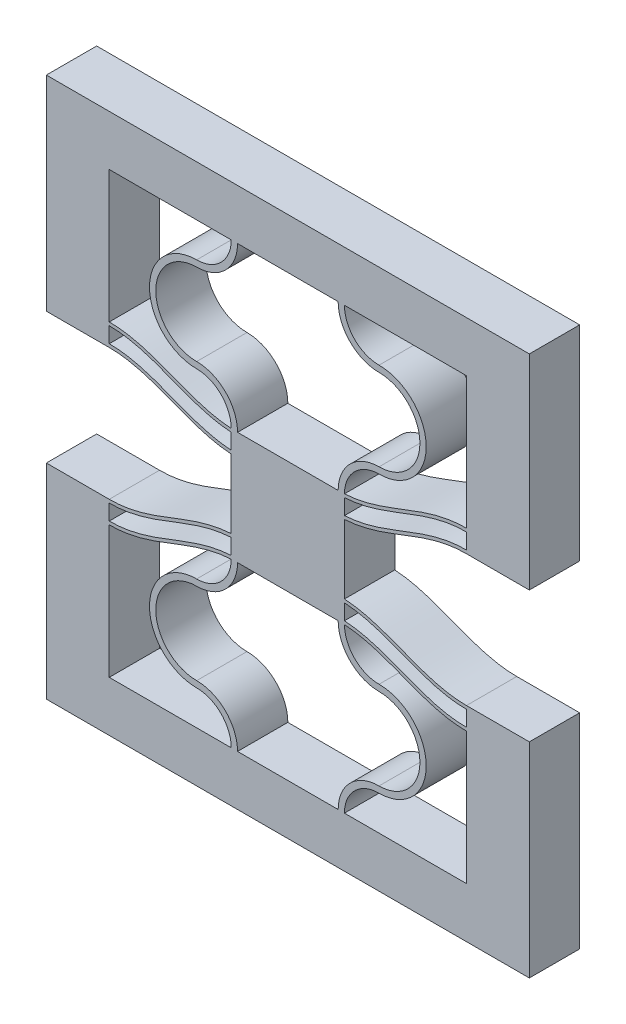
from build123d import *

# Parameters (mm, degrees)
BOSS_EXTRUDE1_DEPTH = 4
SKETCH4_W           = 1.000079602
SKETCH4_H           = 4
BOSS_EXTRUDE2_DEPTH = 1.5
SKETCH7_W           = 4
SKETCH7_H           = 4
SKETCH7_H_2         = 8.970409071
BOSS_EXTRUDE3_DEPTH = 4


with BuildPart() as part:
    # Sketch1 → Boss-Extrude1 (new body)
    with BuildSketch(Plane.XY):
        with BuildLine():
            add(Edge.make_bspline(
                [(10.700039975, 14.745204536), (10.770772559, 14.741026808), (11.036928883, 14.722362813), (11.497122592, 14.671037325), (12.289279781, 14.528352814), (13.186428125, 14.281886639), (13.972953946, 14.012479628), (14.659814487, 13.755888369), (15.208666695, 13.545451258), (15.665563716, 13.368818224), (16.123450769, 13.194753096), (16.65208653, 13.002369042), (17.160327646, 12.828079612), (17.673887847, 12.669729106), (18.193716878, 12.533320658), (18.599888692, 12.444944264), (18.888931626, 12.391496574), (19.130919694, 12.353423685), (19.325052629, 12.327000657), (19.519580514, 12.304753805), (19.715757224, 12.286804034), (19.909026191, 12.273251391), (20.101721437, 12.264172749), (20.275673832, 12.260758352), (20.359000366, 12.259999604), (20.4, 12.259999604)],
                knots=[0.519813033, 0.519813033, 0.519813033, 0.519813033, 0.519813033, 0.531036625, 0.562073255, 0.593109869, 0.647173692, 0.678210339, 0.693728663, 0.709246987, 0.740283631, 0.755801952, 0.771320274, 0.79835218, 0.825384086, 0.84090241, 0.856420734, 0.86417989, 0.871939045, 0.8796982, 0.887457356, 0.89521651, 0.902975665, 0.910734819, 0.918493974, 0.918493974, 0.918493974, 0.918493974, 0.918493974], degree=4))
            Line((10.700039975, 14.745204536), (10.700039975, 15.985204536))
            Line((10.700039975, 15.985204536), (9.699960373, 15.985204536))
            Line((9.699960373, 15.985204536), (9.699960373, 14.745204536))
            add(Edge.make_bspline(
                [(0, 12.259999604), (0.040999634, 12.259999604), (0.124259479, 12.260758348), (0.355363371, 12.265310827), (0.583318983, 12.278545215), (0.832717182, 12.299192103), (1.123166493, 12.332562429), (1.414830156, 12.374284724), (1.752116289, 12.434526897), (2.206359313, 12.533321163), (2.726048123, 12.669728195), (3.239713703, 12.828081076), (3.7478924, 13.002367086), (4.184493287, 13.161250769), (4.551277809, 13.299188315), (4.917195343, 13.439475144), (5.282809261, 13.580521779), (5.740185056, 13.755889696), (6.427046416, 14.012478612), (7.213571652, 14.281887279), (8.110720324, 14.528352483), (8.902877469, 14.671037458), (9.363071278, 14.722362846), (9.629227699, 14.741026811), (9.699960373, 14.745204536)],
                knots=[0.081506026, 0.081506026, 0.081506026, 0.081506026, 0.081506026, 0.089265181, 0.097024335, 0.112542644, 0.1203018, 0.128060955, 0.143579266, 0.15909759, 0.174615914, 0.20164782, 0.228679726, 0.244198048, 0.259716369, 0.275234691, 0.290753013, 0.306271337, 0.321789661, 0.352826308, 0.406890131, 0.437926745, 0.468963375, 0.480186981, 0.480186981, 0.480186981, 0.480186981, 0.480186981], degree=4))
            Line((0, 12.259999604), (-5.000000005, 12.259999604))
            Line((-5.000000005, 12.259999604), (-5.000000005, -4))
            Line((-5.000000005, -4), (25.400000005, -4))
            Line((25.400000005, -4), (25.400000005, 12.259999604))
            Line((25.400000005, 12.259999604), (20.4, 12.259999604))
        make_face()
        with BuildLine():
            Line((9.699960373, 14.485204536), (9.699960373, 13.245204536))
            add(Edge.make_bspline(
                [(0, 10.759999604), (0.040999634, 10.759999604), (0.124259479, 10.760758348), (0.355363371, 10.765310827), (0.583318983, 10.778545215), (0.832717182, 10.799192103), (1.123166493, 10.832562429), (1.414830156, 10.874284724), (1.752116289, 10.934526897), (2.206359313, 11.033321163), (2.726048123, 11.169728195), (3.239713703, 11.328081076), (3.7478924, 11.502367086), (4.184493287, 11.661250769), (4.551277809, 11.799188315), (4.917195343, 11.939475144), (5.282809261, 12.080521779), (5.740185056, 12.255889696), (6.427046416, 12.512478612), (7.213571652, 12.781887279), (8.110720324, 13.028352483), (8.902877469, 13.171037458), (9.363071278, 13.222362846), (9.629227699, 13.241026811), (9.699960373, 13.245204536)],
                knots=[0.081506026, 0.081506026, 0.081506026, 0.081506026, 0.081506026, 0.089265181, 0.097024335, 0.112542644, 0.1203018, 0.128060955, 0.143579266, 0.15909759, 0.174615914, 0.20164782, 0.228679726, 0.244198048, 0.259716369, 0.275234691, 0.290753013, 0.306271337, 0.321789661, 0.352826308, 0.406890131, 0.437926745, 0.468963375, 0.480186981, 0.480186981, 0.480186981, 0.480186981, 0.480186981], degree=4))
            Line((0, 10.759999604), (0, 11.999999604))
            add(Edge.make_bspline(
                [(0, 11.999999604), (0.040999634, 11.999999604), (0.124259479, 12.000758348), (0.355363371, 12.005310827), (0.583318983, 12.018545215), (0.832717182, 12.039192103), (1.123166493, 12.072562429), (1.414830156, 12.114284724), (1.752116289, 12.174526897), (2.206359313, 12.273321163), (2.726048123, 12.409728195), (3.239713703, 12.568081076), (3.7478924, 12.742367086), (4.184493287, 12.901250769), (4.551277809, 13.039188315), (4.917195343, 13.179475144), (5.282809261, 13.320521779), (5.740185056, 13.495889696), (6.427046416, 13.752478612), (7.213571652, 14.021887279), (8.110720324, 14.268352483), (8.902877469, 14.411037458), (9.363071278, 14.462362846), (9.629227699, 14.481026811), (9.699960373, 14.485204536)],
                knots=[0.081506026, 0.081506026, 0.081506026, 0.081506026, 0.081506026, 0.089265181, 0.097024335, 0.112542644, 0.1203018, 0.128060955, 0.143579266, 0.15909759, 0.174615914, 0.20164782, 0.228679726, 0.244198048, 0.259716369, 0.275234691, 0.290753013, 0.306271337, 0.321789661, 0.352826308, 0.406890131, 0.437926745, 0.468963375, 0.480186981, 0.480186981, 0.480186981, 0.480186981, 0.480186981], degree=4))
        make_face(mode=Mode.SUBTRACT)
        with BuildLine():
            Line((10.700039975, 13.245204536), (10.700039975, 14.485204536))
            add(Edge.make_bspline(
                [(10.700039975, 14.485204536), (10.770772559, 14.481026808), (11.036928883, 14.462362813), (11.497122592, 14.411037325), (12.289279781, 14.268352814), (13.186428125, 14.021886639), (13.972953947, 13.752479628), (14.659814487, 13.495888369), (15.208666695, 13.285451258), (15.665563716, 13.108818224), (16.123450769, 12.934753096), (16.65208653, 12.742369042), (17.160327646, 12.568079612), (17.673887847, 12.409729106), (18.193716878, 12.273320658), (18.599888692, 12.184944264), (18.888931626, 12.131496574), (19.130919694, 12.093423685), (19.325052629, 12.067000657), (19.519580514, 12.044753805), (19.715757224, 12.026804034), (19.909026191, 12.013251391), (20.101721437, 12.004172749), (20.275673832, 12.000758352), (20.359000366, 11.999999604), (20.4, 11.999999604)],
                knots=[0.519813033, 0.519813033, 0.519813033, 0.519813033, 0.519813033, 0.531036625, 0.562073255, 0.593109869, 0.647173692, 0.678210339, 0.693728663, 0.709246987, 0.740283631, 0.755801952, 0.771320274, 0.79835218, 0.825384086, 0.84090241, 0.856420734, 0.86417989, 0.871939045, 0.8796982, 0.887457356, 0.89521651, 0.902975665, 0.910734819, 0.918493974, 0.918493974, 0.918493974, 0.918493974, 0.918493974], degree=4))
            Line((20.4, 11.999999604), (20.4, 10.759999604))
            add(Edge.make_bspline(
                [(10.700039975, 13.245204536), (10.770772559, 13.241026808), (11.036928883, 13.222362813), (11.497122592, 13.171037325), (12.289279781, 13.028352814), (13.186428125, 12.781886639), (13.972953947, 12.512479628), (14.659814487, 12.255888369), (15.208666695, 12.045451258), (15.665563716, 11.868818224), (16.123450769, 11.694753096), (16.65208653, 11.502369042), (17.160327646, 11.328079612), (17.673887847, 11.169729106), (18.193716878, 11.033320658), (18.599888692, 10.944944264), (18.888931626, 10.891496574), (19.130919694, 10.853423685), (19.325052629, 10.827000657), (19.519580514, 10.804753805), (19.715757224, 10.786804034), (19.909026191, 10.773251391), (20.101721437, 10.764172749), (20.275673832, 10.760758352), (20.359000366, 10.759999604), (20.4, 10.759999604)],
                knots=[0.519813033, 0.519813033, 0.519813033, 0.519813033, 0.519813033, 0.531036625, 0.562073255, 0.593109869, 0.647173692, 0.678210339, 0.693728663, 0.709246987, 0.740283631, 0.755801952, 0.771320274, 0.79835218, 0.825384086, 0.84090241, 0.856420734, 0.86417989, 0.871939045, 0.8796982, 0.887457356, 0.89521651, 0.902975665, 0.910734819, 0.918493974, 0.918493974, 0.918493974, 0.918493974, 0.918493974], degree=4))
        make_face(mode=Mode.SUBTRACT)
        with BuildLine():
            Line((0, 0), (0, 10.499999604))
            add(Edge.make_bspline(
                [(0, 10.499999604), (0.040999634, 10.499999604), (0.124259479, 10.500758348), (0.355363371, 10.505310827), (0.583318983, 10.518545215), (0.832717182, 10.539192103), (1.123166493, 10.572562429), (1.414830156, 10.614284724), (1.752116289, 10.674526897), (2.206359313, 10.773321163), (2.726048123, 10.909728195), (3.239713703, 11.068081076), (3.7478924, 11.242367086), (4.184493287, 11.401250769), (4.551277809, 11.539188315), (4.917195343, 11.679475144), (5.282809261, 11.820521779), (5.740185056, 11.995889696), (6.427046416, 12.252478612), (7.213571652, 12.521887279), (8.110720324, 12.768352483), (8.902877469, 12.911037458), (9.363071278, 12.962362846), (9.629227699, 12.981026811), (9.699960373, 12.985204536)],
                knots=[0.081506026, 0.081506026, 0.081506026, 0.081506026, 0.081506026, 0.089265181, 0.097024335, 0.112542644, 0.1203018, 0.128060955, 0.143579266, 0.15909759, 0.174615914, 0.20164782, 0.228679726, 0.244198048, 0.259716369, 0.275234691, 0.290753013, 0.306271337, 0.321789661, 0.352826308, 0.406890131, 0.437926745, 0.468963375, 0.480186981, 0.480186981, 0.480186981, 0.480186981, 0.480186981], degree=4))
            ThreePointArc((9.699960373, 12.985204536), (8.889305781, 11.050232382), (6.950000174, 10.25))
            ThreePointArc((6.950000174, 10.25), (3.200000174, 6.5), (6.950000174, 2.75))
            ThreePointArc((6.950000174, 2.75), (8.894543822, 1.944543648), (9.700000174, 0))
            Line((9.700000174, 0), (0, 0))
        make_face(mode=Mode.SUBTRACT)
        with BuildLine():
            ThreePointArc((6.950000174, 9.75), (9.248097213, 10.701902961), (10.200000174, 13))
            ThreePointArc((10.200000174, 13), (11.151903135, 10.701902961), (13.450000174, 9.75))
            ThreePointArc((13.450000174, 9.75), (16.700000174, 6.5), (13.450000174, 3.25))
            ThreePointArc((13.450000174, 3.25), (11.151903135, 2.298097039), (10.200000174, 0))
            ThreePointArc((10.200000174, 0), (9.248097213, 2.298097039), (6.950000174, 3.25))
            ThreePointArc((6.950000174, 3.25), (3.700000174, 6.5), (6.950000174, 9.75))
        make_face(mode=Mode.SUBTRACT)
        with BuildLine():
            ThreePointArc((13.450000174, 10.25), (11.510694567, 11.050232382), (10.700039975, 12.985204536))
            add(Edge.make_bspline(
                [(10.700039975, 12.985204536), (10.770772559, 12.981026808), (11.036928883, 12.962362813), (11.497122592, 12.911037325), (12.289279781, 12.768352814), (13.186428125, 12.521886639), (13.972953947, 12.252479628), (14.659814487, 11.995888369), (15.208666695, 11.785451258), (15.665563716, 11.608818224), (16.123450769, 11.434753096), (16.65208653, 11.242369042), (17.160327646, 11.068079612), (17.673887847, 10.909729106), (18.193716878, 10.773320658), (18.599888692, 10.684944264), (18.888931626, 10.631496574), (19.130919694, 10.593423685), (19.325052629, 10.567000657), (19.519580514, 10.544753805), (19.715757224, 10.526804034), (19.909026191, 10.513251391), (20.101721437, 10.504172749), (20.275673832, 10.500758352), (20.359000366, 10.499999604), (20.4, 10.499999604)],
                knots=[0.519813033, 0.519813033, 0.519813033, 0.519813033, 0.519813033, 0.531036625, 0.562073255, 0.593109869, 0.647173692, 0.678210339, 0.693728663, 0.709246987, 0.740283631, 0.755801952, 0.771320274, 0.79835218, 0.825384086, 0.84090241, 0.856420734, 0.86417989, 0.871939045, 0.8796982, 0.887457356, 0.89521651, 0.902975665, 0.910734819, 0.918493974, 0.918493974, 0.918493974, 0.918493974, 0.918493974], degree=4))
            Line((20.4, 10.499999604), (20.4, 0))
            Line((20.4, 0), (10.700000174, 0))
            ThreePointArc((10.700000174, 0), (11.505456526, 1.944543648), (13.450000174, 2.75))
            ThreePointArc((13.450000174, 2.75), (17.200000174, 6.5), (13.450000174, 10.25))
        make_face(mode=Mode.SUBTRACT)
    extrude(amount=BOSS_EXTRUDE1_DEPTH)

    # Sketch4 → Boss-Extrude2 (add)
    with BuildSketch(Plane(origin=(0, 15.985204536, 0), x_dir=(1, 0, 0), z_dir=(0, 1, 0))):
        with Locations((10.200000174, -2)):
            Rectangle(SKETCH4_W, SKETCH4_H)
    extrude(amount=BOSS_EXTRUDE2_DEPTH)

    # Mirror3: part across plane


with BuildPart() as part_1:
    add(part.part)
    add(part.part.mirror(Plane.ZX.offset(17.485204536)))

    # Split2
    split(bisect_by=Plane(origin=(10.200000174, 0, 0), x_dir=(0, -1, 0), z_dir=(-1, 0, 0)), keep=Keep.BOTTOM)

    # Sketch7 → Boss-Extrude3 (add)
    with BuildSketch(Plane.ZY.offset(-10.200000174)):
        with Locations((2, 36.970409071)):
            Rectangle(SKETCH7_W, SKETCH7_H)
        with Locations((2, 17.485204536)):
            Rectangle(SKETCH7_W, SKETCH7_H_2)
        with Locations((2, -2)):
            Rectangle(SKETCH7_W, SKETCH7_H)
    extrude(amount=BOSS_EXTRUDE3_DEPTH)

    # Mirror2: part across plane


with BuildPart() as part_2:
    add(part_1.part)
    add(part_1.part.mirror(Plane.ZY.offset(-6.200000174)))


solid = part_2.part
